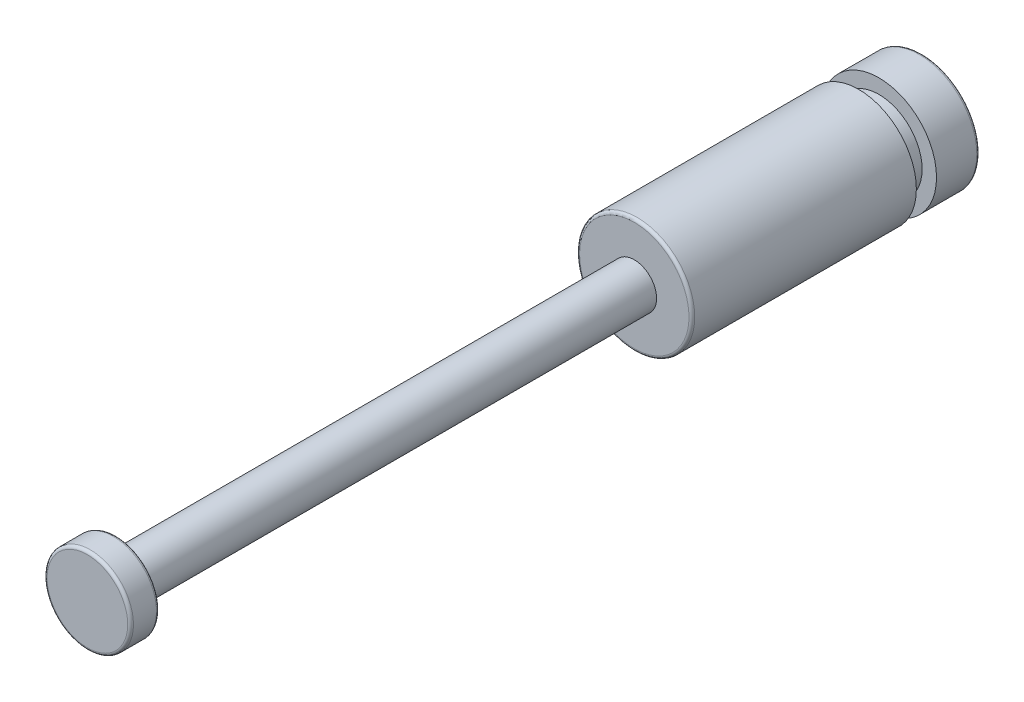
from build123d import *

# Parameters (mm, degrees)
SKETCH1_R           = 0.775
BOSS_EXTRUDE1_DEPTH = 18
SKETCH2_R           = 1.5
BOSS_EXTRUDE2_DEPTH = 1
SKETCH3_R           = 2
BOSS_EXTRUDE4_DEPTH = 10
SKETCH5_W           = 0.7
SKETCH5_H           = 0.5
FILLET1_R           = 0.1


with BuildPart() as part:
    # Sketch1 → Boss-Extrude1 (new body)
    with BuildSketch(Plane.XY):
        Circle(SKETCH1_R)
    extrude(amount=BOSS_EXTRUDE1_DEPTH)

    # Sketch2 → Boss-Extrude2 (add)
    with BuildSketch(Plane.XY.offset(18)):
        Circle(SKETCH2_R)
    extrude(amount=BOSS_EXTRUDE2_DEPTH)

    # Sketch3 → Boss-Extrude4 (add)
    with BuildSketch(Plane(origin=(0, 0, 0), x_dir=(-1, 0, 0), z_dir=(0, 0, -1))):
        Circle(SKETCH3_R)
    extrude(amount=BOSS_EXTRUDE4_DEPTH)

    # Sketch5 → Cut-Revolve1 (revolve, cut)
    with BuildSketch(Plane(origin=(0, 0, 0), x_dir=(0, 0, -1), z_dir=(1, 0, 0))):
        with Locations((8.15, 1.75)):
            Rectangle(SKETCH5_W, SKETCH5_H)
    revolve(axis=Axis((0, 0, 0), (0, 0, -1)), mode=Mode.SUBTRACT)

    # Fillet1
    fillet1_edges = [part.edges().sort_by_distance(p)[0] for p in [
        (-1.5, 0, 18),
        (-1.5, 0, 19),
        (2, 0, 0),
        (2, 0, -10),
    ]]
    fillet(fillet1_edges, radius=FILLET1_R)


solid = part.part
